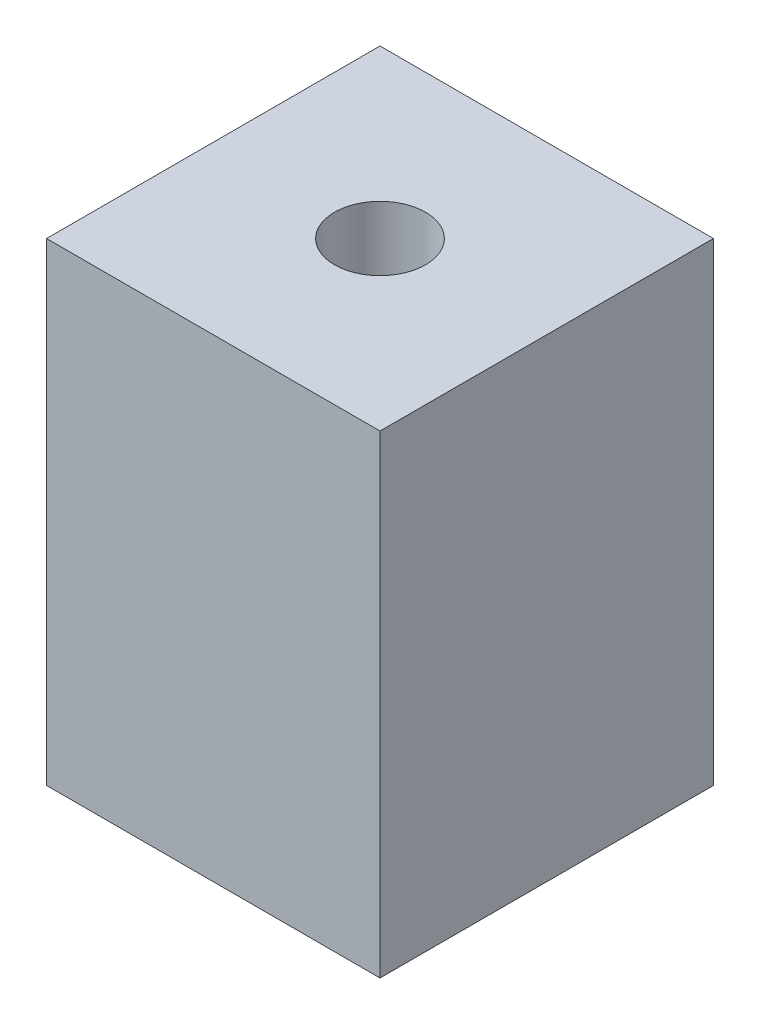
from build123d import *

# Parameters (mm, degrees)
SKETCH2_W           = 46.482
SKETCH2_H           = 46.482
BOSS_EXTRUDE1_DEPTH = 66.04
SKETCH3_R           = 6.35
CUT_EXTRUDE1_DEPTH  = 12.7
SKETCH4_R           = 6.35
CUT_EXTRUDE2_DEPTH  = 12.7


with BuildPart() as part:
    # Sketch2 → Boss-Extrude1 (new body)
    with BuildSketch(Plane(origin=(0, 0, 0), x_dir=(1, 0, 0), z_dir=(0, 1, 0))):
        Rectangle(SKETCH2_W, SKETCH2_H)
    extrude(amount=BOSS_EXTRUDE1_DEPTH)

    # Sketch3 → Cut-Extrude1 (cut)
    with BuildSketch(Plane(origin=(0, 66.04, 0), x_dir=(1, 0, 0), z_dir=(0, 1, 0))):
        Circle(SKETCH3_R)
    extrude(amount=-CUT_EXTRUDE1_DEPTH, mode=Mode.SUBTRACT)

    # Sketch4 → Cut-Extrude2 (cut)
    with BuildSketch(Plane.XZ):
        Circle(SKETCH4_R)
    extrude(amount=-CUT_EXTRUDE2_DEPTH, mode=Mode.SUBTRACT)


solid = part.part
